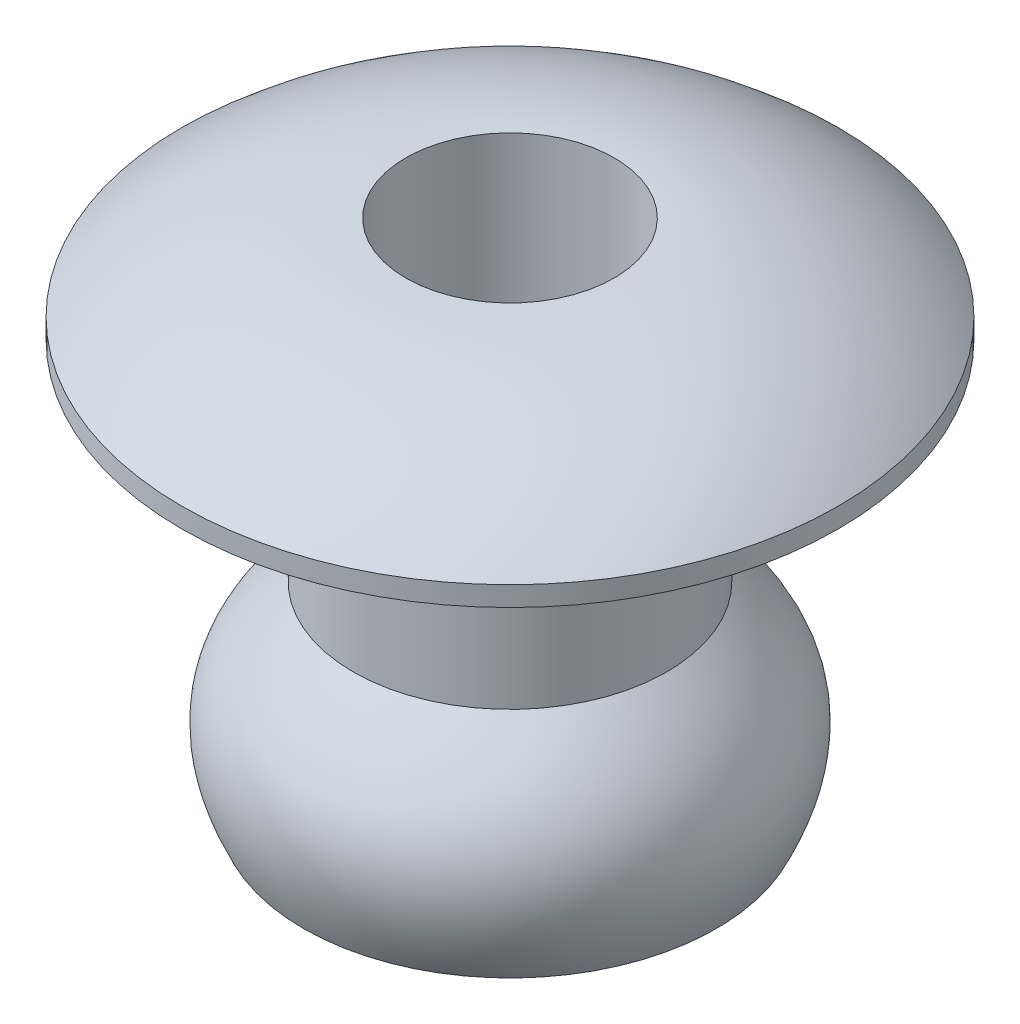
from build123d import *


with BuildPart() as part:
    # Sketch1 → Revolve1 (revolve)
    with BuildSketch(Plane(origin=(0, 0, 0), x_dir=(0, 0, -1), z_dir=(1, 0, 0))):
        with BuildLine():
            Line((-2.38125, 0), (-2.38125, -3.175))
            add(Edge.make_bspline(
                [(-3.13125, -6.175), (-3.802952342, -4.79609431), (-3.285209116, -3.987769359), (-2.38125, -3.175)],
                knots=[0, 0, 0, 0, 0.915818095, 0.915818095, 0.915818095, 0.915818095], degree=3))
            Line((-3.13125, -6.175), (-2.401327057, -6.175))
            ThreePointArc((-2.401327057, -6.175), (-2.316535213, -6.12801267), (-2.311426216, -6.031206863))
            Line((-2.311426216, -6.031206863), (-2.412043273, -5.824654907))
            add(Edge.make_bspline(
                [(-2.412043273, -5.824654907), (-2.471633315, -5.702325353), (-2.583928673, -5.423792478), (-2.638657915, -5.140257692), (-2.638916412, -4.911036675), (-2.582141845, -4.65282889), (-2.426240405, -4.370567896), (-2.139321349, -4.043102642), (-1.942255168, -3.85611024), (-1.846366913, -3.769895018)],
                knots=[0, 0, 0, 0, 0.114477262, 0.228954524, 0.343431786, 0.457909047, 0.686863571, 0.801340833, 0.915818095, 0.915818095, 0.915818095, 0.915818095], degree=3))
            Line((-1.846366913, -3.769895018), (-1.58125, -3.531522619))
            Line((-1.58125, -3.531522619), (-1.58125, 1.6002))
            ThreePointArc((-1.58125, 1.6002), (-3.399982262, 1.264045733), (-4.9784, 0.3))
            Line((-4.9784, 0.3), (-4.9784, 0))
            Line((-4.9784, 0), (-2.38125, 0))
        make_face()
    revolve(axis=Axis((0, 0, 0), (0, -1, 0)))


solid = part.part
